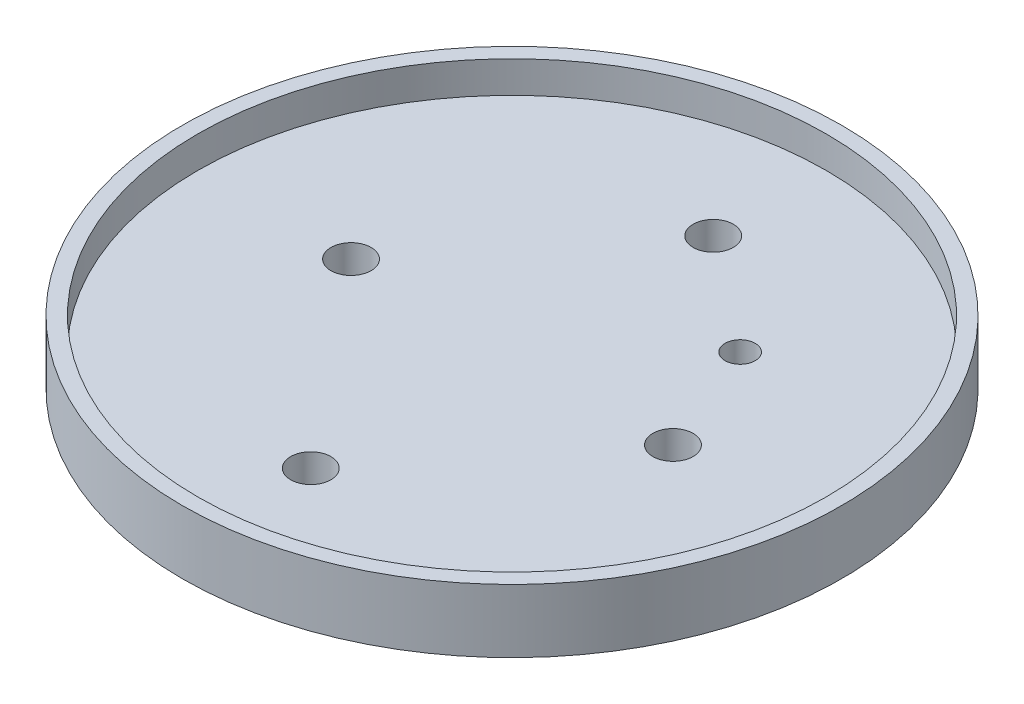
from build123d import *

# Parameters (mm, degrees)
SKETCH1_R           = 52
SKETCH1_R_2         = 3.175
SKETCH1_R_3         = 2.38
BOSS_EXTRUDE1_DEPTH = 5
SKETCH2_R           = 52
SKETCH2_R_2         = 49.6
BOSS_EXTRUDE2_DEPTH = 5


with BuildPart() as part:
    # Sketch1 → Boss-Extrude1 (new body)
    with BuildSketch(Plane(origin=(0, 0, 0), x_dir=(1, 0, 0), z_dir=(0, 1, 0))):
        Circle(SKETCH1_R)
        with Locations((25.4, 0)):
            Circle(SKETCH1_R_2, mode=Mode.SUBTRACT)
        with Locations((0, 31.75)):
            Circle(SKETCH1_R_2, mode=Mode.SUBTRACT)
        with Locations((-25.4, 0)):
            Circle(SKETCH1_R_2, mode=Mode.SUBTRACT)
        with Locations((0, -31.75)):
            Circle(SKETCH1_R_2, mode=Mode.SUBTRACT)
        with Locations((18, 18)):
            Circle(SKETCH1_R_3, mode=Mode.SUBTRACT)
    extrude(amount=BOSS_EXTRUDE1_DEPTH)

    # Sketch2 → Boss-Extrude2 (add)
    with BuildSketch(Plane(origin=(0, 5, 0), x_dir=(1, 0, 0), z_dir=(0, 1, 0))):
        Circle(SKETCH2_R)
        Circle(SKETCH2_R_2, mode=Mode.SUBTRACT)
    extrude(amount=BOSS_EXTRUDE2_DEPTH)


solid = part.part
